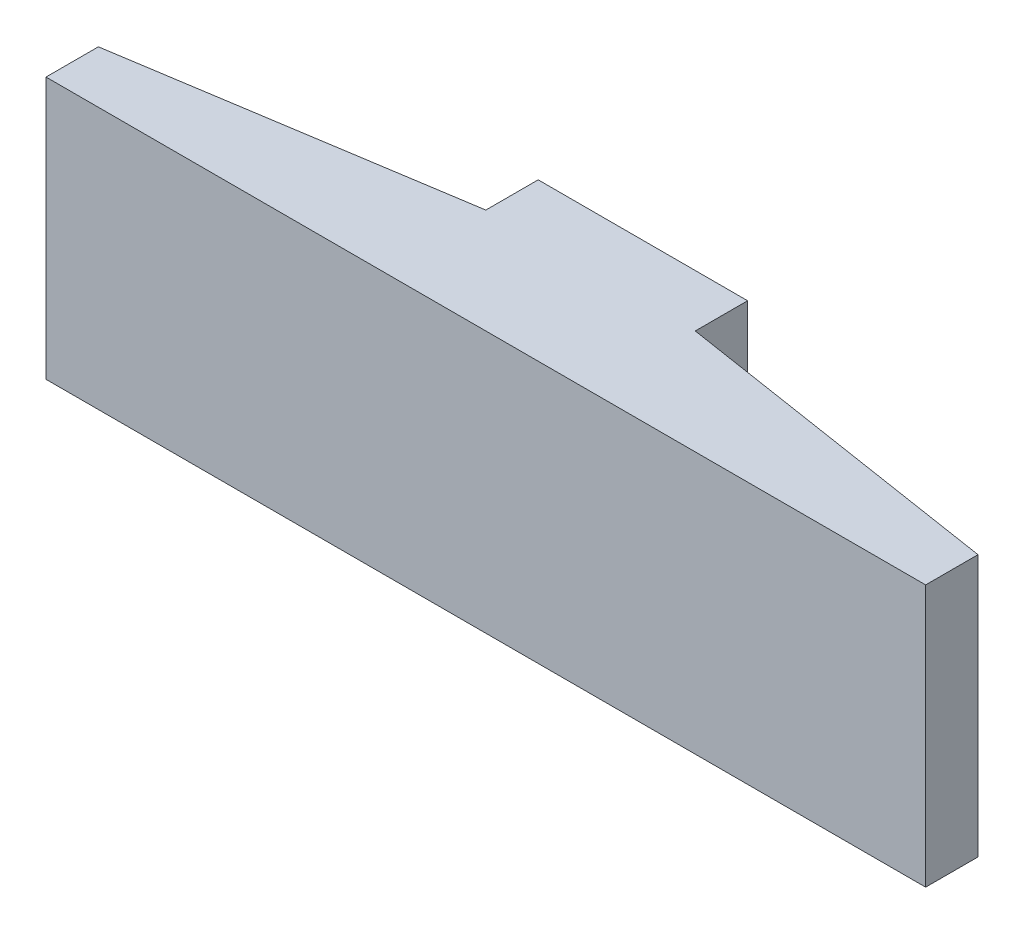
from build123d import *

# Parameters (mm, degrees)
P_IDAT_VYSUNUT_M1_DEPTH = 2.5


with BuildPart() as part:
    # Skica1 → Přidat vysunutím1 (new body)
    with BuildSketch(Plane(origin=(0, 0, 0), x_dir=(1, 0, 0), z_dir=(0, 1, 0))):
        Polygon((4.2, -0.75), (-4.2, -0.75), (-4.2, -0.25), (-1, 0.25), (-1, 0.75), (1, 0.75), (1, 0.25), (4.2, -0.25), align=None)
    extrude(amount=P_IDAT_VYSUNUT_M1_DEPTH)


solid = part.part
